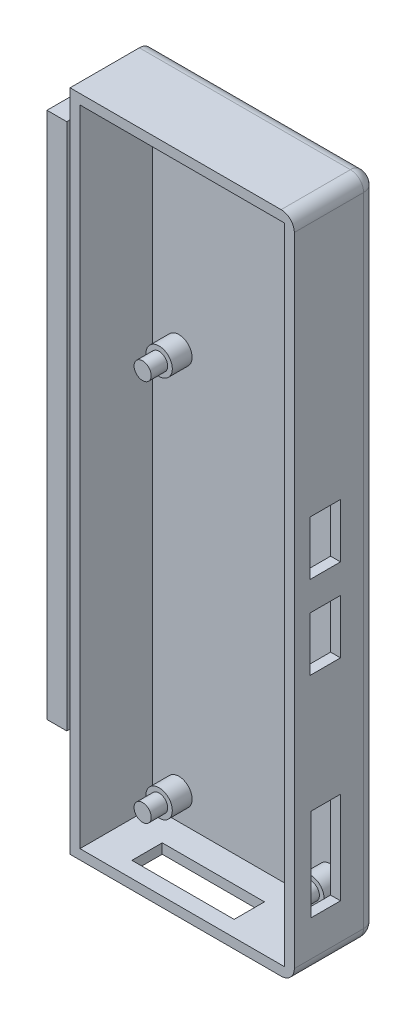
from build123d import *

# Parameters (mm, degrees)
ESQUISSE1_W             = 34
ESQUISSE1_H             = 100.65
BOSS_EXTRU_1_DEPTH      = 12.5
ESQUISSE2_W             = 31
ESQUISSE2_H             = 97.65
ENL_V_MAT_EXTRU_1_DEPTH = 11
ESQUISSE5_R             = 2
BOSS_EXTRU_4_DEPTH      = 3
ESQUISSE6_R             = 1.3
BOSS_EXTRU_5_DEPTH      = 5.5
CONG_2_R                = 2
CONG_3_R                = 2
CONG_4_R                = 2
ESQUISSE7_W             = 7.5
ESQUISSE7_H             = 80
BOSS_EXTRU_6_DEPTH      = 1
ESQUISSE9_W             = 10
ESQUISSE9_H             = 80
BOSS_EXTRU_7_DEPTH      = 3
ESQUISSE10_W            = 4.6
ESQUISSE10_H            = 8.2
ESQUISSE10_W_2          = 4.5
ESQUISSE10_H_2          = 14
ENL_V_MAT_EXTRU_2_DEPTH = 3
ESQUISSE11_W            = 15.5
ESQUISSE11_H            = 4.6
ENL_V_MAT_EXTRU_3_DEPTH = 3


with BuildPart() as part:
    # Esquisse1 → Boss.-Extru.1 (new body)
    with BuildSketch(Plane.XY):
        with Locations((17, 50.325)):
            Rectangle(ESQUISSE1_W, ESQUISSE1_H)
    extrude(amount=BOSS_EXTRU_1_DEPTH)

    # Esquisse2 → Enlèv. mat.-Extru.1 (cut)
    with BuildSketch(Plane.XY.offset(12.5)):
        with Locations((17, 50.325)):
            Rectangle(ESQUISSE2_W, ESQUISSE2_H)
    extrude(amount=-ENL_V_MAT_EXTRU_1_DEPTH, mode=Mode.SUBTRACT)

    # Esquisse5 → Boss.-Extru.4 (add)
    with BuildSketch(Plane.XY.offset(1.5)):
        with Locations((5.5, 63.5)):
            Circle(ESQUISSE5_R)
        with Locations((28.5, 63.5)):
            Circle(ESQUISSE5_R)
        with Locations((5.5, 5.5)):
            Circle(ESQUISSE5_R)
        with Locations((28.5, 5.5)):
            Circle(ESQUISSE5_R)
    extrude(amount=BOSS_EXTRU_4_DEPTH)

    # Esquisse6 → Boss.-Extru.5 (add)
    with BuildSketch(Plane.XY.offset(1.5)):
        with Locations((5.5, 63.5)):
            Circle(ESQUISSE6_R)
        with Locations((28.5, 63.5)):
            Circle(ESQUISSE6_R)
        with Locations((5.5, 5.5)):
            Circle(ESQUISSE6_R)
        with Locations((28.5, 5.5)):
            Circle(ESQUISSE6_R)
    extrude(amount=BOSS_EXTRU_5_DEPTH)

    # Congé2
    cong_2_edges = [part.edges().sort_by_distance(p)[0] for p in [
        (34, 0, 6.25),
    ]]
    fillet(cong_2_edges, radius=CONG_2_R)

    # Congé3
    cong_3_edges = [part.edges().sort_by_distance(p)[0] for p in [
        (34, 100.65, 6.25),
    ]]
    fillet(cong_3_edges, radius=CONG_3_R)

    # Congé4
    cong_4_edges = [part.edges().sort_by_distance(p)[0] for p in [
        (16, 0, 0),
        (34, 50.325, 0),
        (33.414213562, 0.585786438, 0),
        (16, 100.65, 0),
        (33.414213562, 100.064213562, 0),
    ]]
    fillet(cong_4_edges, radius=CONG_4_R)

    # Esquisse7 → Boss.-Extru.6 (add)
    with BuildSketch(Plane.ZY):
        with Locations((7, 55.45)):
            Rectangle(ESQUISSE7_W, ESQUISSE7_H)
    extrude(amount=BOSS_EXTRU_6_DEPTH)

    # Esquisse9 → Boss.-Extru.7 (add)
    with BuildSketch(Plane.ZY.offset(1)):
        with Locations((7, 55.45)):
            Rectangle(ESQUISSE9_W, ESQUISSE9_H)
    extrude(amount=BOSS_EXTRU_7_DEPTH)

    # Esquisse10 → Enlèv. mat.-Extru.2 (cut)
    with BuildSketch(Plane.ZY.offset(-32.5)):
        with Locations((7.8, 56)):
            Rectangle(ESQUISSE10_W, ESQUISSE10_H)
        with Locations((7.8, 43.4)):
            Rectangle(ESQUISSE10_W, ESQUISSE10_H)
        with Locations((7.75, 14.4)):
            Rectangle(ESQUISSE10_W_2, ESQUISSE10_H_2)
    extrude(amount=-ENL_V_MAT_EXTRU_2_DEPTH, mode=Mode.SUBTRACT)

    # Esquisse11 → Enlèv. mat.-Extru.3 (cut)
    with BuildSketch(Plane(origin=(0, 1.5, 0), x_dir=(1, 0, 0), z_dir=(0, 1, 0))):
        with Locations((14.724178104, -7.8)):
            Rectangle(ESQUISSE11_W, ESQUISSE11_H)
    extrude(amount=-ENL_V_MAT_EXTRU_3_DEPTH, mode=Mode.SUBTRACT)


solid = part.part
